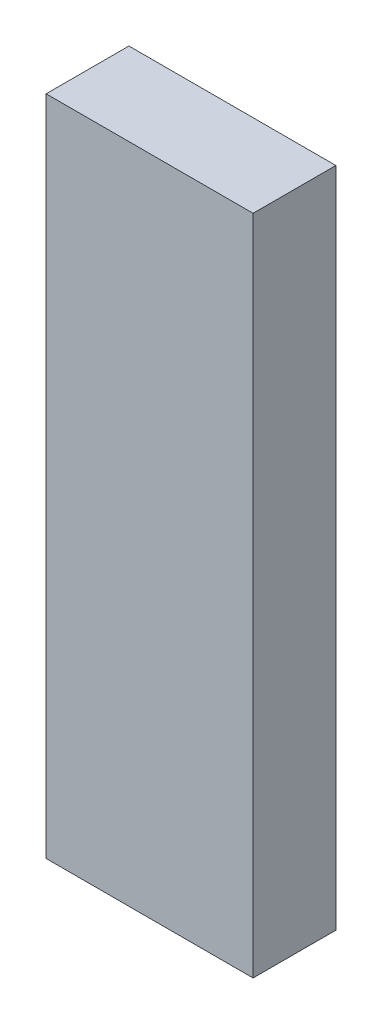
from build123d import *

# Parameters (mm, degrees)
SKETCH1_W           = 63.5
SKETCH1_H           = 25.4
BOSS_EXTRUDE1_DEPTH = 101.6


with BuildPart() as part:
    # Sketch1 → Boss-Extrude1 (new body, symmetric)
    with BuildSketch(Plane(origin=(0, 0, 0), x_dir=(1, 0, 0), z_dir=(0, 1, 0))):
        Rectangle(SKETCH1_W, SKETCH1_H)
    extrude(amount=BOSS_EXTRUDE1_DEPTH, both=True)


solid = part.part
